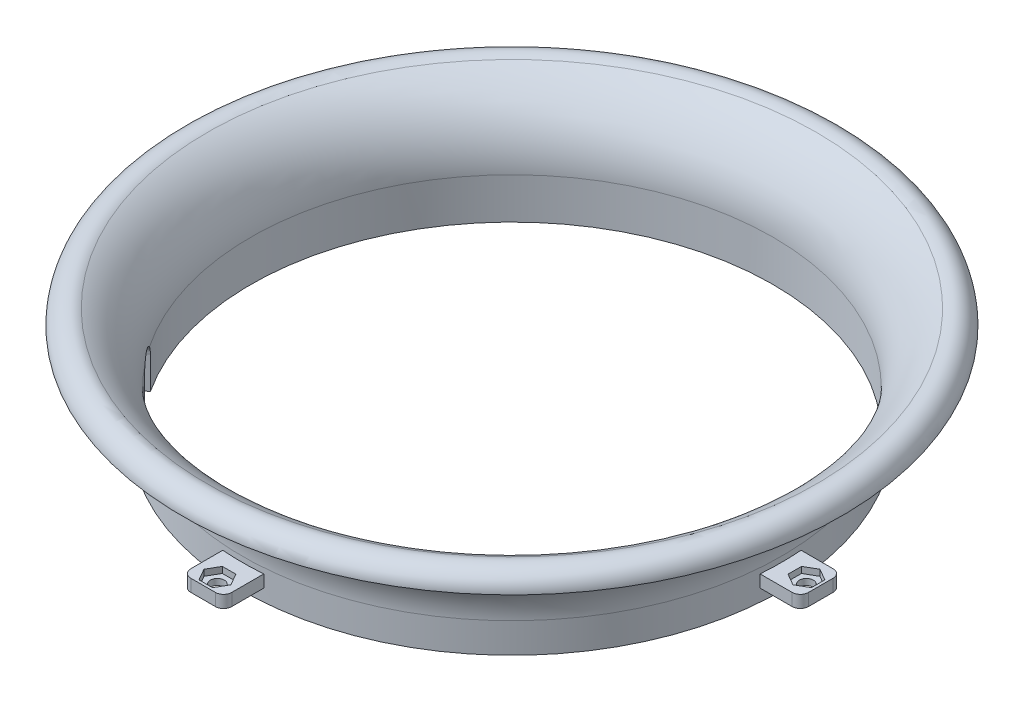
from build123d import *

# Parameters (mm, degrees)
BOSS_EXTRUDE1_DEPTH = 3
SKETCH5_R           = 1.7
CUT_EXTRUDE2_DEPTH  = 116.718915703
CUT_EXTRUDE1_DEPTH  = 1.5
CIRPATTERN13_COUNT  = 4
CUT_EXTRUDE3_DEPTH  = 122.389186915


with BuildPart() as part:
    # Sketch1 → Revolve1 (revolve)
    with BuildSketch(Plane.XY):
        with BuildLine():
            Line((63.75, 18.737026277), (63.75, 25.098484685))
            ThreePointArc((63.75, 25.098484685), (66.610296039, 35.058746011), (74.319544881, 41.983742863))
            ThreePointArc((74.319544881, 41.983742863), (78.398172265, 41.784089154), (80.425886783, 38.239595286))
            ThreePointArc((80.425886783, 38.239595286), (69.983309328, 33.20133547), (65.75, 22.407328891))
            Line((65.75, 22.407328891), (65.75, 18.737026277))
            Line((65.75, 18.737026277), (65.75, 15.098484685))
            Line((65.75, 15.098484685), (63.75, 15.098484685))
            Line((63.75, 15.098484685), (63.75, 18.737026277))
        make_face()
    revolve(axis=Axis((0, 0, 0), (0, 1, 0)))

    # Sketch3 → Boss-Extrude1 (add)
    with BuildSketch(Plane(origin=(0, 18.098484685, 0), x_dir=(-1, 0, 0), z_dir=(0, -1, 0))):
        with BuildLine():
            Line((65.55961028, 5), (73.36961028, 5))
            ThreePointArc((73.36961028, 5), (74.783823842, 4.414213562), (75.36961028, 3))
            Line((75.36961028, 3), (75.36961028, -3))
            ThreePointArc((75.36961028, -3), (74.783823842, -4.414213562), (73.36961028, -5))
            Line((73.36961028, -5), (65.55961028, -5))
            ThreePointArc((65.55961028, -5), (65.75, 0), (65.55961028, 5))
        make_face()
    boss_extrude1 = extrude(amount=-BOSS_EXTRUDE1_DEPTH)

    # Sketch5 → Cut-Extrude2 (cut, through all)
    with BuildSketch(Plane(origin=(0, 21.098484685, 0), x_dir=(1, 0, 0), z_dir=(0, 1, 0))):
        with Locations((-71.86961028, 0)):
            Circle(SKETCH5_R)
    cut_extrude2 = extrude(amount=-CUT_EXTRUDE2_DEPTH, mode=Mode.SUBTRACT)

    # Sketch4 → Cut-Extrude1 (cut)
    with BuildSketch(Plane(origin=(0, 21.098484685, 0), x_dir=(1, 0, 0), z_dir=(0, 1, 0))):
        Polygon((-71.86961028, 3.290896534), (-74.71961028, 1.645448267), (-74.71961028, -1.645448267), (-71.86961028, -3.290896534), (-69.01961028, -1.645448267), (-69.01961028, 1.645448267), align=None)
    cut_extrude1 = extrude(amount=-CUT_EXTRUDE1_DEPTH, mode=Mode.SUBTRACT)

    # CirPattern13: Boss-Extrude1, Cut-Extrude2, Cut-Extrude1 ×4 about axis
    cirpattern13_axis = Axis((0, 0, 0), (0, -1, 0))
    add([boss_extrude1.rotate(cirpattern13_axis, i * 360 / CIRPATTERN13_COUNT) for i in range(1, CIRPATTERN13_COUNT)])
    add([cut_extrude2.rotate(cirpattern13_axis, i * 360 / CIRPATTERN13_COUNT) for i in range(1, CIRPATTERN13_COUNT)], mode=Mode.SUBTRACT)
    add([cut_extrude1.rotate(cirpattern13_axis, i * 360 / CIRPATTERN13_COUNT) for i in range(1, CIRPATTERN13_COUNT)], mode=Mode.SUBTRACT)

    # Sketch6 → Cut-Extrude3 (cut, through all)
    with BuildSketch(Plane(origin=(0, 0, 0), x_dir=(0, 1, 0), z_dir=(0.8090169943749466, 0, -0.5877852522924742))):
        with BuildLine():
            Line((21, 3.175), (15.098484685, 3.175))
            Line((15.098484685, 3.175), (15.098484685, -3.175))
            Line((15.098484685, -3.175), (21, -3.175))
            Line((21, -3.175), (23, -3.175))
            ThreePointArc((23, -3.175), (26.175, 0), (23, 3.175))
            Line((23, 3.175), (21, 3.175))
        make_face()
    extrude(amount=-CUT_EXTRUDE3_DEPTH, mode=Mode.SUBTRACT)


solid = part.part
